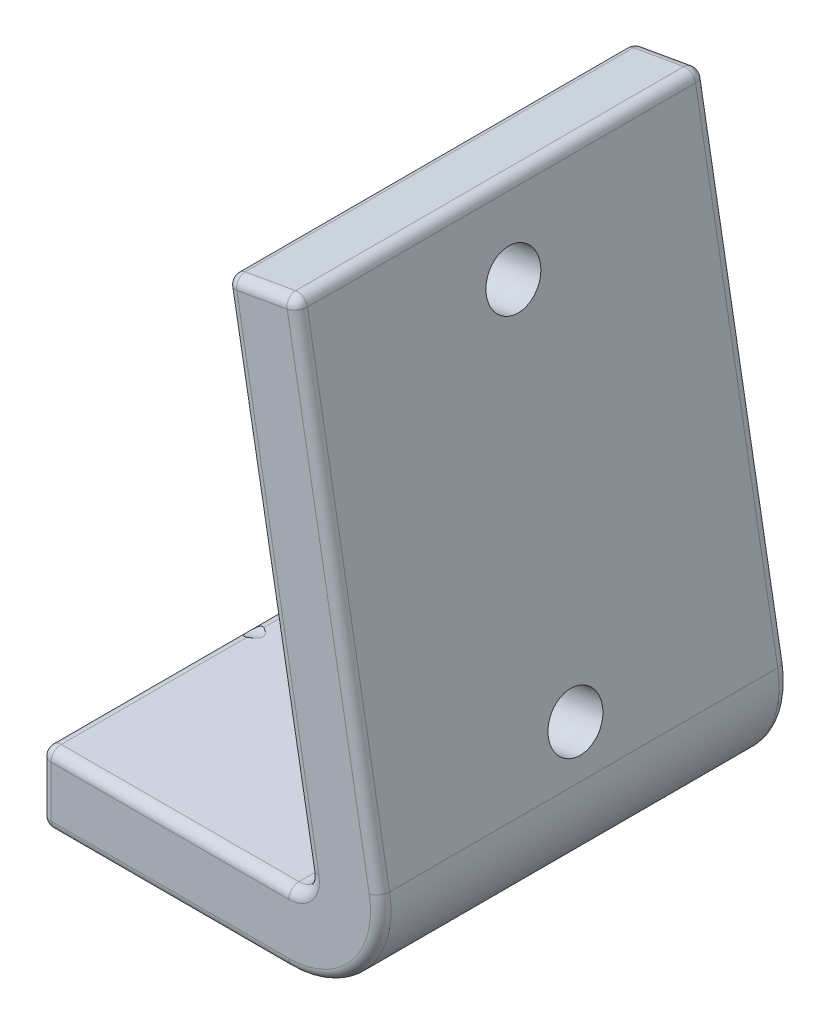
from build123d import *

# Parameters (mm, degrees)
BOSS_EXTRUDE1_DEPTH = 20
FILLET2_R           = 2
FILLET3_R           = 9
FILLET1_R           = 1
HOLE1_D             = 5.3


with BuildPart() as part:
    # Sketch2 → Boss-Extrude1 (new, symmetric)
    with BuildSketch(Plane.XY):
        Polygon((0, 0), (-35, 0), (-35, 7), (-8.342275148, 7), (-16.965248576, 55.903312431), (-10.071594305, 57.118849675), align=None)
    extrude(amount=BOSS_EXTRUDE1_DEPTH, both=True)

    # Fillet2
    fillet2_edges = [part.edges().sort_by_distance(p)[0] for p in [
        (-8.342275148, 7, 0),
    ]]
    fillet(fillet2_edges, radius=FILLET2_R)

    # Fillet3
    fillet3_edges = [part.edges().sort_by_distance(p)[0] for p in [
        (0, 0, 0),
    ]]
    fillet(fillet3_edges, radius=FILLET3_R)

    # Fillet1
    fillet1_edges = [part.edges().sort_by_distance(p)[0] for p in [
        (-22.862891167, 0, 20),
        (-22.862891167, 7, 20),
        (-12.860707702, 32.625304393, 20),
        (-5.96705343, 33.840841637, 20),
        (-35, 7, 0),
        (-35, 3.5, 20),
        (-35, 0, 0),
        (-35, 3.5, -20),
        (-10.071594305, 57.118849675, 0),
        (-13.51842144, 56.511081053, 20),
        (-16.965248576, 55.903312431, 0),
        (-13.51842144, 56.511081053, -20),
        (-9.193693447, 7.714424781, 20),
        (-3.831382345, 3.214911513, 20),
        (-12.860707702, 32.625304393, -20),
        (-9.193693447, 7.714424781, -20),
        (-22.862891167, 7, -20),
        (-22.862891167, 0, -20),
        (-3.831382345, 3.214911513, -20),
        (-5.96705343, 33.840841637, -20),
    ]]
    fillet(fillet1_edges, radius=FILLET1_R)

    # Hole1 (through all)
    with Locations(Plane(origin=(0, 0, 0), x_dir=(0, 0, -1), z_dir=(0.984807753012208, 0.17364817766693083, 0))):
        with Locations((0, 50.31616731), (0, 15.31616731)):
            Hole(HOLE1_D / 2)


solid = part.part
